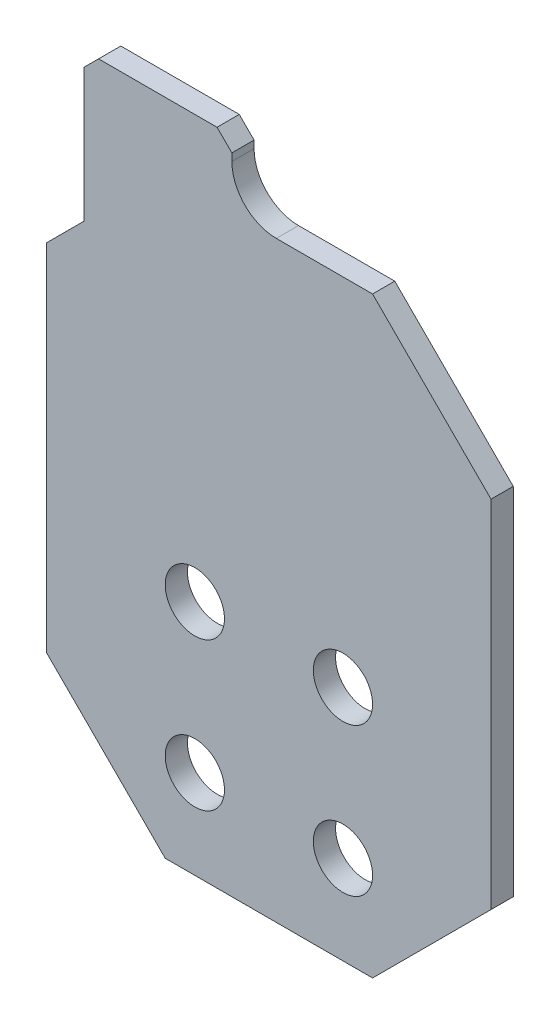
from build123d import *

# Parameters (mm, degrees)
SKETCH1_W           = 30
SKETCH1_H           = 40
SKETCH1_R           = 2
BOSS_EXTRUDE1_DEPTH = 1.5
CHAMFER1_SIZE       = 8
SKETCH2_W           = 10
SKETCH2_H           = 10
BOSS_EXTRUDE2_DEPTH = 1.5
CHAMFER3_SIZE       = 1
FILLET1_R           = 3


with BuildPart() as part:
    # Sketch1 → Boss-Extrude1 (new body)
    with BuildSketch(Plane.XY):
        with Locations((15, -20)):
            Rectangle(SKETCH1_W, SKETCH1_H)
        with Locations((20, -34)):
            Circle(SKETCH1_R, mode=Mode.SUBTRACT)
        with Locations((10, -34)):
            Circle(SKETCH1_R, mode=Mode.SUBTRACT)
        with Locations((20, -24)):
            Circle(SKETCH1_R, mode=Mode.SUBTRACT)
        with Locations((10, -24)):
            Circle(SKETCH1_R, mode=Mode.SUBTRACT)
    extrude(amount=BOSS_EXTRUDE1_DEPTH)

    # Chamfer1
    chamfer1_edges = [part.edges().sort_by_distance(p)[0] for p in [
        (0, 0, 0.75),
        (30, 0, 0.75),
        (30, -40, 0.75),
        (0, -40, 0.75),
    ]]
    chamfer(chamfer1_edges, length=CHAMFER1_SIZE)

    # Sketch2 → Boss-Extrude2 (add)
    with BuildSketch(Plane.XY.offset(1.5)):
        with Locations((7.5, -0.5)):
            Rectangle(SKETCH2_W, SKETCH2_H)
    extrude(amount=-BOSS_EXTRUDE2_DEPTH)

    # Chamfer3
    chamfer3_edges = [part.edges().sort_by_distance(p)[0] for p in [
        (12.5, 4.5, 0.75),
        (2.5, 4.5, 0.75),
    ]]
    chamfer(chamfer3_edges, length=CHAMFER3_SIZE)

    # Fillet1
    fillet1_edges = [part.edges().sort_by_distance(p)[0] for p in [
        (12.5, 0, 0.75),
    ]]
    fillet(fillet1_edges, radius=FILLET1_R)


solid = part.part
